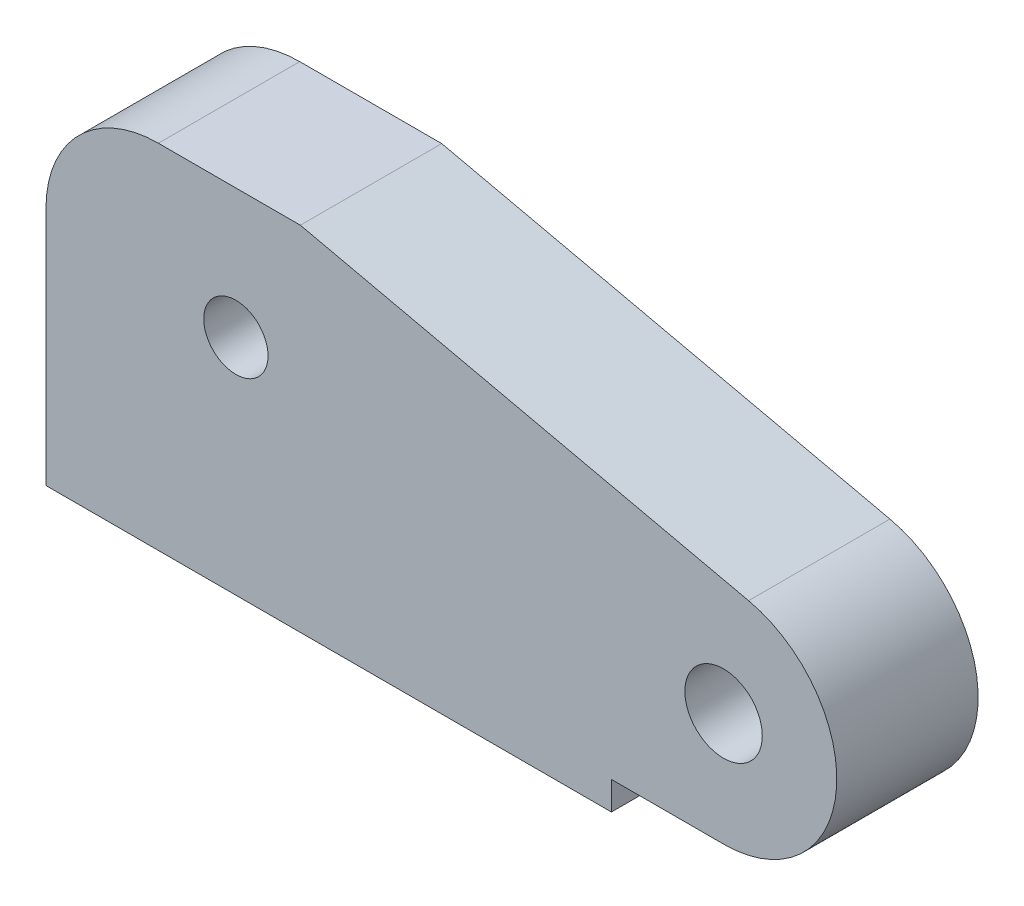
from build123d import *

# Parameters (mm, degrees)
CROQUIS1_R              = 2.273640803
CROQUIS1_R_2            = 2.739354484
SALIENTE_EXTRUIR1_DEPTH = 10


with BuildPart() as part:
    # Croquis1 → Saliente-Extruir1 (new body)
    with BuildSketch(Plane.XY):
        with BuildLine():
            Line((-58.5, -33.5), (-58.5, -16.5))
            ThreePointArc((-58.5, -16.5), (-56.171439372, -10.87835735), (-50.549796722, -8.549796722))
            Line((-50.549796722, -8.549796722), (-40.505582208, -8.549796722))
            Line((-40.505582208, -8.549796722), (-8.795660821, -15.698566958))
            ThreePointArc((-8.795660821, -15.698566958), (-2.605899054, -24.392438678), (-10.567, -31.5))
            Line((-10.567, -31.5), (-18.5, -31.5))
            Line((-18.5, -31.5), (-18.5, -33.5))
            Line((-18.5, -33.5), (-58.5, -33.5))
        make_face()
        with Locations((-45.067, -17.7)):
            Circle(CROQUIS1_R, mode=Mode.SUBTRACT)
        with Locations((-10.567, -23.5)):
            Circle(CROQUIS1_R_2, mode=Mode.SUBTRACT)
    extrude(amount=SALIENTE_EXTRUIR1_DEPTH)


solid = part.part
